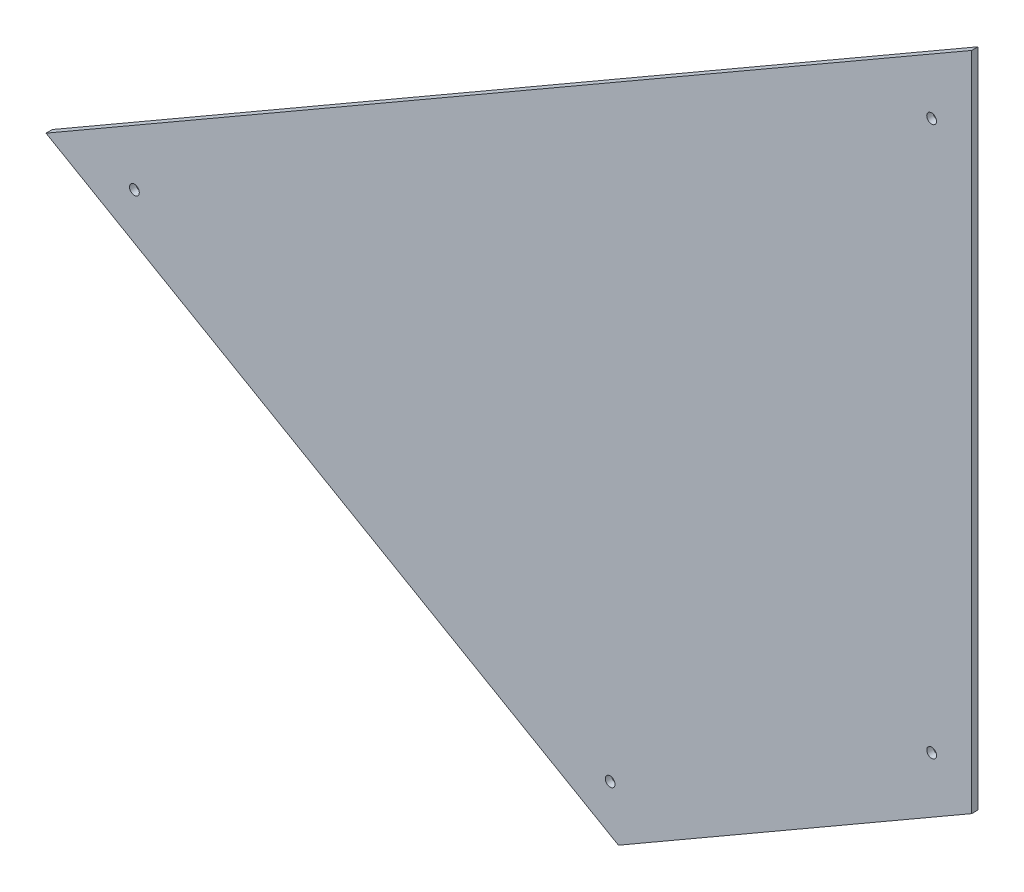
from build123d import *

# Parameters (mm, degrees)
EXTRUDE_1_DEPTH     = 2
SKETCH_3_R          = 1.55
CUT_EXTRUDE_1_DEPTH = 2


with BuildPart() as part:
    # Эскиз1 → Бобышка-Вытянуть1 (new body)
    with BuildSketch(Plane.XY):
        Polygon((0, 0), (-293.143158486, -169.261155122), (-111.86100446, -273.906060772), (0, -209.31740407), align=None)
    extrude(amount=EXTRUDE_1_DEPTH)

    # Эскиз3 → Вырез-Вытянуть1 (cut)
    with BuildSketch(Plane(origin=(0, 0, 0), x_dir=(-1, 0, 0), z_dir=(0, 0, -1))):
        with Locations((12.682716025, -25.001847817)):
            Circle(SKETCH_3_R)
        with Locations((12.682716025, -198.961582281)):
            Circle(SKETCH_3_R)
        with Locations((114.489281174, -257.744795592)):
            Circle(SKETCH_3_R)
        with Locations((265.149449722, -170.776394274)):
            Circle(SKETCH_3_R)
    extrude(amount=-CUT_EXTRUDE_1_DEPTH, mode=Mode.SUBTRACT)


solid = part.part
